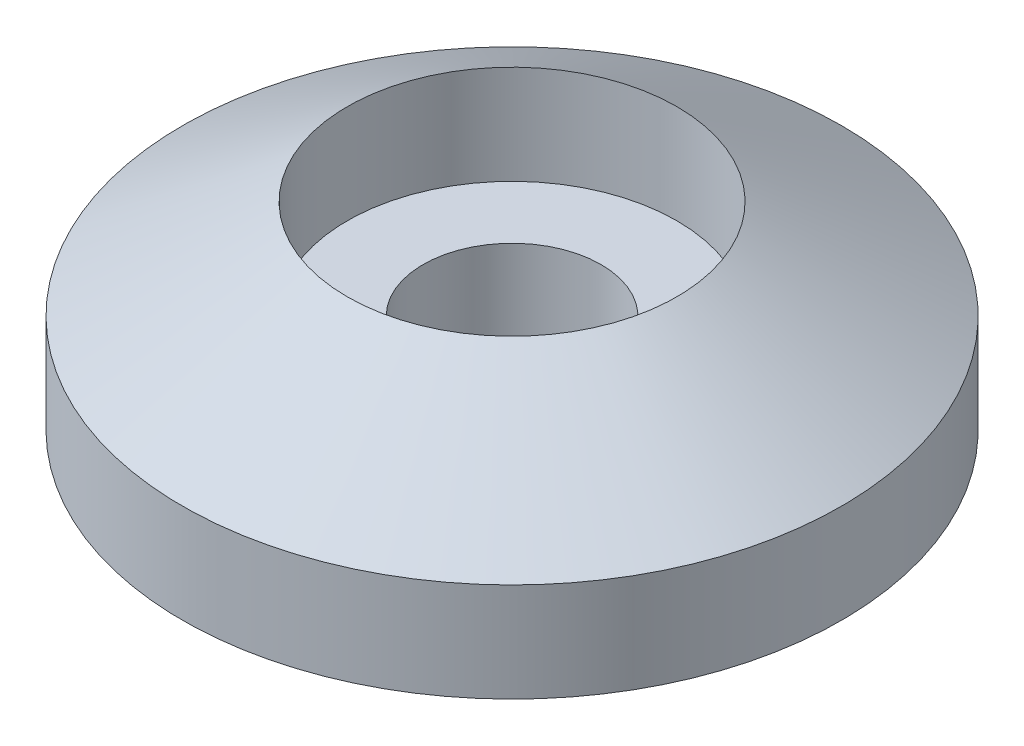
from build123d import *


with BuildPart() as part:
    # Sketch1 → Revolve1 (revolve)
    with BuildSketch(Plane.XY):
        Polygon((-10, 3), (-10, 0), (-2.7, 0), (-2.7, 3), (-5, 3), (-5, 6), align=None)
    revolve(axis=Axis((0, 0, 0), (0, 1, 0)))


solid = part.part
